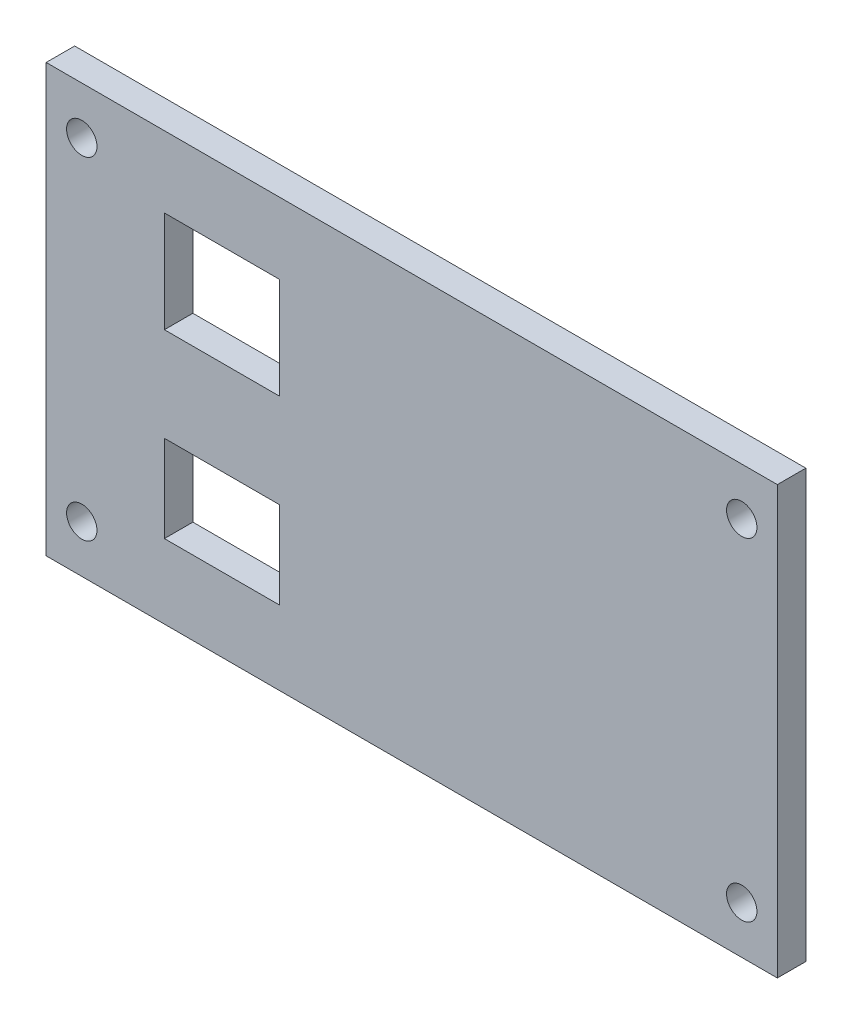
from build123d import *

# Parameters (mm, degrees)
CROQUIS1_W              = 77
CROQUIS1_H              = 45
SALIENTE_EXTRUIR1_DEPTH = 3
CORTAR_EXTRUIR1_REACH   = 5
CROQUIS2_R              = 1.6
CROQUIS2_W              = 12.1
CROQUIS2_H              = 10.65
CROQUIS2_H_2            = 9.15


with BuildPart() as part:
    # Croquis1 → Saliente-Extruir1 (new body)
    with BuildSketch(Plane.XY):
        Rectangle(CROQUIS1_W, CROQUIS1_H)
    extrude(amount=SALIENTE_EXTRUIR1_DEPTH)

    # Croquis2 → Cortar-Extruir1 (cut, up to next)
    with BuildSketch(Plane(origin=(0, 0, 0), x_dir=(-1, 0, 0), z_dir=(0, 0, -1)), mode=Mode.PRIVATE) as cortar_extruir1_sk1:
        with Locations((34.75, 17.5)):
            Circle(CROQUIS2_R)
    cortar_extruir1_tool1 = extrude(cortar_extruir1_sk1.sketch, amount=-CORTAR_EXTRUIR1_REACH, mode=Mode.PRIVATE) & part.part
    add(cortar_extruir1_tool1.solids().sort_by_distance((-34.75, 17.5, 0))[0], mode=Mode.SUBTRACT)
    # Croquis2 → Cortar-Extruir1 (cut, up to next)
    with BuildSketch(Plane(origin=(0, 0, 0), x_dir=(-1, 0, 0), z_dir=(0, 0, -1)), mode=Mode.PRIVATE) as cortar_extruir1_sk2:
        with Locations((-34.75, 17.5)):
            Circle(CROQUIS2_R)
    cortar_extruir1_tool2 = extrude(cortar_extruir1_sk2.sketch, amount=-CORTAR_EXTRUIR1_REACH, mode=Mode.PRIVATE) & part.part
    add(cortar_extruir1_tool2.solids().sort_by_distance((34.75, 17.5, 0))[0], mode=Mode.SUBTRACT)
    # Croquis2 → Cortar-Extruir1 (cut, up to next)
    with BuildSketch(Plane(origin=(0, 0, 0), x_dir=(-1, 0, 0), z_dir=(0, 0, -1)), mode=Mode.PRIVATE) as cortar_extruir1_sk3:
        with Locations((-34.75, -17.5)):
            Circle(CROQUIS2_R)
    cortar_extruir1_tool3 = extrude(cortar_extruir1_sk3.sketch, amount=-CORTAR_EXTRUIR1_REACH, mode=Mode.PRIVATE) & part.part
    add(cortar_extruir1_tool3.solids().sort_by_distance((34.75, -17.5, 0))[0], mode=Mode.SUBTRACT)
    # Croquis2 → Cortar-Extruir1 (cut, up to next)
    with BuildSketch(Plane(origin=(0, 0, 0), x_dir=(-1, 0, 0), z_dir=(0, 0, -1)), mode=Mode.PRIVATE) as cortar_extruir1_sk4:
        with Locations((34.75, -17.5)):
            Circle(CROQUIS2_R)
    cortar_extruir1_tool4 = extrude(cortar_extruir1_sk4.sketch, amount=-CORTAR_EXTRUIR1_REACH, mode=Mode.PRIVATE) & part.part
    add(cortar_extruir1_tool4.solids().sort_by_distance((-34.75, -17.5, 0))[0], mode=Mode.SUBTRACT)
    # Croquis2 → Cortar-Extruir1 (cut, up to next)
    with BuildSketch(Plane(origin=(0, 0, 0), x_dir=(-1, 0, 0), z_dir=(0, 0, -1)), mode=Mode.PRIVATE) as cortar_extruir1_sk5:
        with Locations((20, 9.675)):
            Rectangle(CROQUIS2_W, CROQUIS2_H)
    cortar_extruir1_tool5 = extrude(cortar_extruir1_sk5.sketch, amount=-CORTAR_EXTRUIR1_REACH, mode=Mode.PRIVATE) & part.part
    add(cortar_extruir1_tool5.solids().sort_by_distance((-20, 9.675, 0))[0], mode=Mode.SUBTRACT)
    # Croquis2 → Cortar-Extruir1 (cut, up to next)
    with BuildSketch(Plane(origin=(0, 0, 0), x_dir=(-1, 0, 0), z_dir=(0, 0, -1)), mode=Mode.PRIVATE) as cortar_extruir1_sk6:
        with Locations((20, -10.125)):
            Rectangle(CROQUIS2_W, CROQUIS2_H_2)
    cortar_extruir1_tool6 = extrude(cortar_extruir1_sk6.sketch, amount=-CORTAR_EXTRUIR1_REACH, mode=Mode.PRIVATE) & part.part
    add(cortar_extruir1_tool6.solids().sort_by_distance((-20, -10.125, 0))[0], mode=Mode.SUBTRACT)


solid = part.part
